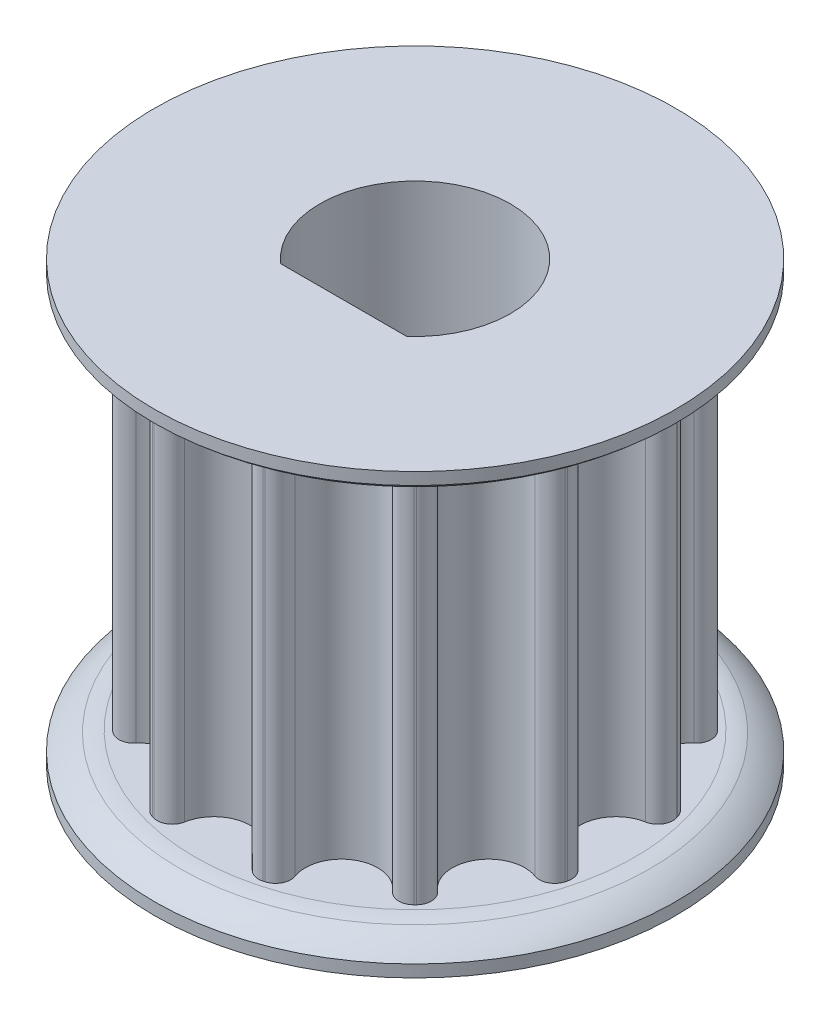
from build123d import *

# Parameters (mm, degrees)
SKETCH1_R           = 8.977796406
TOOTHOD_DEPTH       = 7.9375
TOOTHPROFILE_DEPTH  = 16.875
TOOTHPATTERN_COUNT  = 12
SKETCH7_R           = 4
BORE_DEPTH          = 10.2075
BORE_DEPTH_BACK     = 10.2075
BOSS_EXTRUDE1_START = -2.54
BOSS_EXTRUDE1_DEPTH = 15.875


with BuildPart() as part:
    # Sketch1 → ToothOD (new body, symmetric)
    with BuildSketch(Plane(origin=(0, 0, 0), x_dir=(1, 0, 0), z_dir=(0, 1, 0))):
        Circle(SKETCH1_R)
    extrude(amount=TOOTHOD_DEPTH, both=True)

    # Sketch2 → ToothProfile (cut, through all)
    with BuildSketch(Plane(origin=(0, 7.9375, 0), x_dir=(1, 0, 0), z_dir=(0, 1, 0))):
        with BuildLine():
            ThreePointArc((-1.501752794, 8.177535128), (0, 6.917796406), (1.501752794, 8.177535128))
            ThreePointArc((1.501752794, 8.177535128), (1.784898523, 8.602004268), (2.28897191, 8.681096469))
            ThreePointArc((2.28897191, 8.681096469), (0, 8.977796406), (-2.28897191, 8.681096469))
            ThreePointArc((-2.28897191, 8.681096469), (-1.784898523, 8.602004268), (-1.501752794, 8.177535128))
        make_face()
    toothprofile = extrude(amount=-TOOTHPROFILE_DEPTH, mode=Mode.SUBTRACT)

    # ToothPattern: ToothProfile ×12 about axis
    toothpattern_axis = Axis((0, 0, 0), (0, 1, 0))
    for i in range(1, TOOTHPATTERN_COUNT):
        add(toothprofile.rotate(toothpattern_axis, i * 360 / TOOTHPATTERN_COUNT), mode=Mode.SUBTRACT)

    # Sketch4 → Flange (revolve)
    with BuildSketch(Plane.XY):
        with BuildLine():
            Line((0, -7.9375), (9.231796406, -7.9375))
            ThreePointArc((9.231796406, -7.9375), (9.557552396, -7.963122571), (9.877368734, -8.030137424))
            ThreePointArc((9.877368734, -8.030137424), (10.445097311, -8.311697125), (10.946296406, -8.6995))
            Line((10.946296406, -8.6995), (10.946296406, -9.2075))
            Line((10.946296406, -9.2075), (0, -9.2075))
            Line((0, -9.2075), (0, -7.9375))
        make_face()
        with BuildLine():
            Line((10.946296406, 9.2075), (10.946296406, 8.6995))
            ThreePointArc((10.946296406, 8.6995), (10.445097311, 8.311697125), (9.877368734, 8.030137424))
            ThreePointArc((9.877368734, 8.030137424), (9.557552396, 7.963122571), (9.231796406, 7.9375))
            Line((9.231796406, 7.9375), (0, 7.9375))
            Line((0, 7.9375), (0, 9.2075))
            Line((0, 9.2075), (10.946296406, 9.2075))
        make_face()
    revolve(axis=Axis((0, 12.09802, 0), (0, -1, 0)))

    # Sketch7 → Bore (cut, two sides)
    with BuildSketch(Plane.XZ) as bore_sk:
        Circle(SKETCH7_R)
    extrude(amount=BORE_DEPTH, mode=Mode.SUBTRACT)
    extrude(bore_sk.sketch, amount=-BORE_DEPTH_BACK, mode=Mode.SUBTRACT)

    # Sketch8 → Boss-Extrude1 (add, through all)
    with BuildSketch(Plane.XZ.offset(9.2075).offset(BOSS_EXTRUDE1_START)):
        with BuildLine():
            Line((-2.645751311, 3), (2.645751311, 3))
            ThreePointArc((2.645751311, 3), (0, 4), (-2.645751311, 3))
        make_face()
    extrude(amount=-BOSS_EXTRUDE1_DEPTH)


solid = part.part
